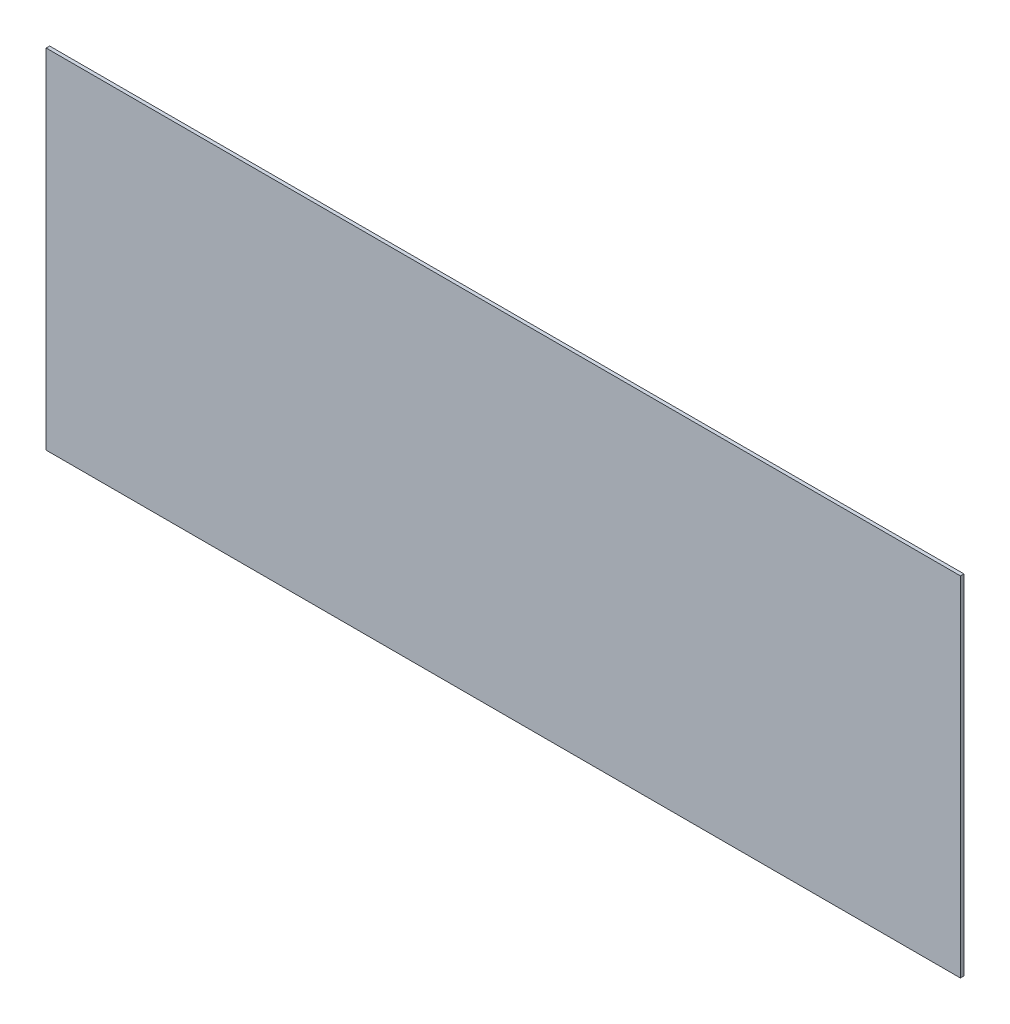
from build123d import *

# Parameters (mm, degrees)
SKETCH1_W           = 66.675
SKETCH1_H           = 25.4
BOSS_EXTRUDE1_DEPTH = 0.254


with BuildPart() as part:
    # Sketch1 → Boss-Extrude1 (new body)
    with BuildSketch(Plane.XY):
        Rectangle(SKETCH1_W, SKETCH1_H)
    extrude(amount=BOSS_EXTRUDE1_DEPTH)


solid = part.part
